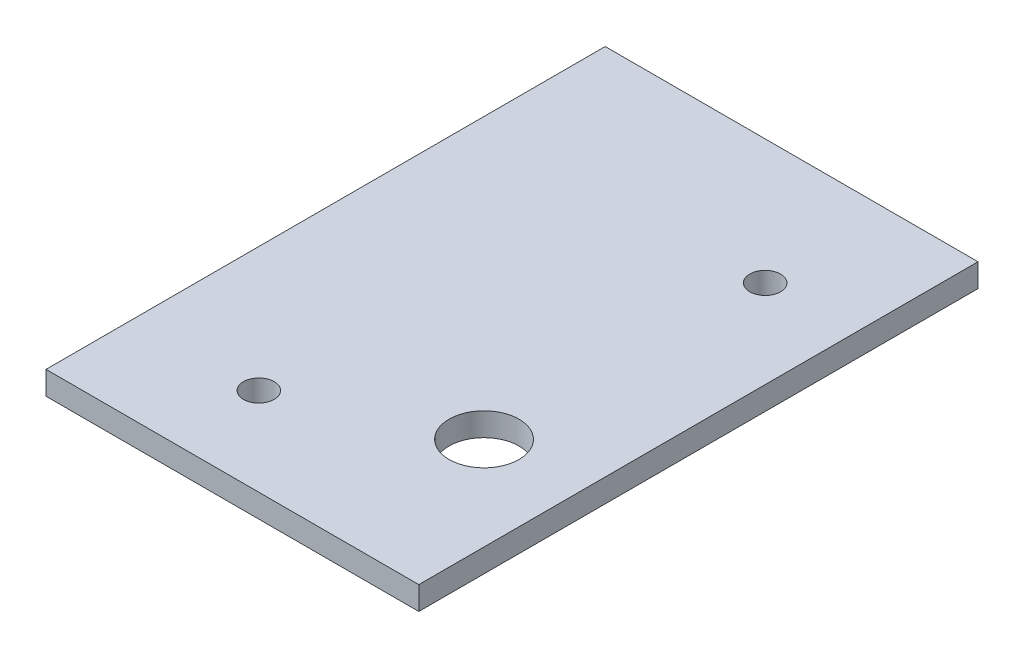
from build123d import *

# Parameters (mm, degrees)
SKETCH1_W           = 50.8
SKETCH1_H           = 76.2
BOSS_EXTRUDE1_DEPTH = 3.175
SKETCH2_R           = 4.7625
CUT_EXTRUDE1_DEPTH  = 4.175
SKETCH3_R           = 2.1
CUT_EXTRUDE2_DEPTH  = 4.175


with BuildPart() as part:
    # Sketch1 → Boss-Extrude1 (new body)
    with BuildSketch(Plane(origin=(0, 0, 0), x_dir=(1, 0, 0), z_dir=(0, 1, 0))):
        Rectangle(SKETCH1_W, SKETCH1_H)
    extrude(amount=BOSS_EXTRUDE1_DEPTH)

    # Sketch2 → Cut-Extrude1 (cut, through all)
    with BuildSketch(Plane(origin=(0, 3.175, 0), x_dir=(1, 0, 0), z_dir=(0, 1, 0))):
        with Locations((12.7, -16.51)):
            Circle(SKETCH2_R)
    extrude(amount=-CUT_EXTRUDE1_DEPTH, mode=Mode.SUBTRACT)

    # Sketch3 → Cut-Extrude2 (cut, through all)
    with BuildSketch(Plane(origin=(0, 3.175, 0), x_dir=(1, 0, 0), z_dir=(0, 1, 0))):
        with Locations((13.4, 21.1)):
            Circle(SKETCH3_R)
        with Locations((-8.4, -26.1)):
            Circle(SKETCH3_R)
    extrude(amount=-CUT_EXTRUDE2_DEPTH, mode=Mode.SUBTRACT)


solid = part.part
